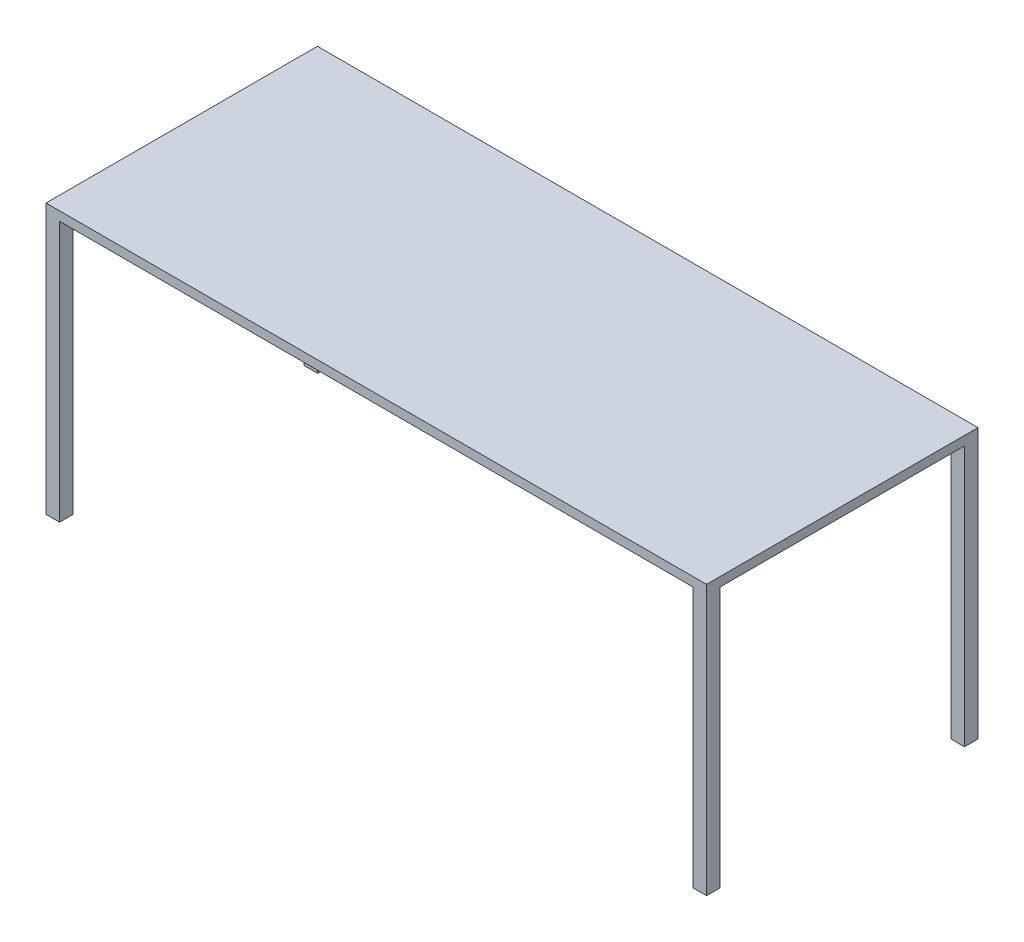
from build123d import *

# Parameters (mm, degrees)
SKETCH1_W           = 1854.2
SKETCH1_H           = 762
BOSS_EXTRUDE1_DEPTH = 756.92
CUT_EXTRUDE1_DEPTH  = 731.52


with BuildPart() as part:
    # Sketch1 → Boss-Extrude1 (new body)
    with BuildSketch(Plane(origin=(0, 0, 0), x_dir=(1, 0, 0), z_dir=(0, 1, 0))):
        Rectangle(SKETCH1_W, SKETCH1_H)
    extrude(amount=BOSS_EXTRUDE1_DEPTH)

    # Sketch2 → Cut-Extrude1 (cut)
    with BuildSketch(Plane.XZ):
        Polygon((-889, 381), (889, 381), (889, 342.9), (927.1, 342.9), (927.1, -342.9), (889, -342.9), (889, -381), (-889, -381), (-889, -342.9), (-927.1, -342.9), (-927.1, 342.9), (-889, 342.9), align=None)
    extrude(amount=-CUT_EXTRUDE1_DEPTH, mode=Mode.SUBTRACT)


solid = part.part
